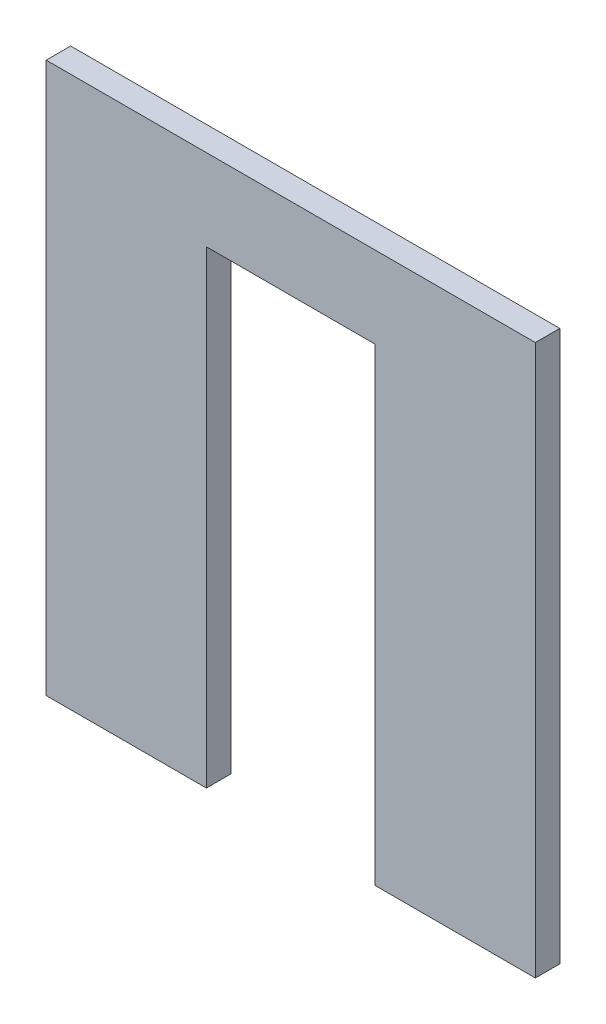
from build123d import *

# Parameters (mm, degrees)
BOSS_EXTRUDE1_DEPTH = 0.003


with BuildPart() as part:
    # Sketch1 → Boss-Extrude1 (new body)
    with BuildSketch(Plane.XY):
        Polygon((0, 0), (0.01965, 0), (0.01965, 0.0575), (0.04035, 0.0575), (0.04035, 0), (0.06, 0), (0.06, 0.055), (0.06, 0.0675), (0, 0.0675), (0, 0.055), align=None)
    extrude(amount=BOSS_EXTRUDE1_DEPTH)


solid = part.part
